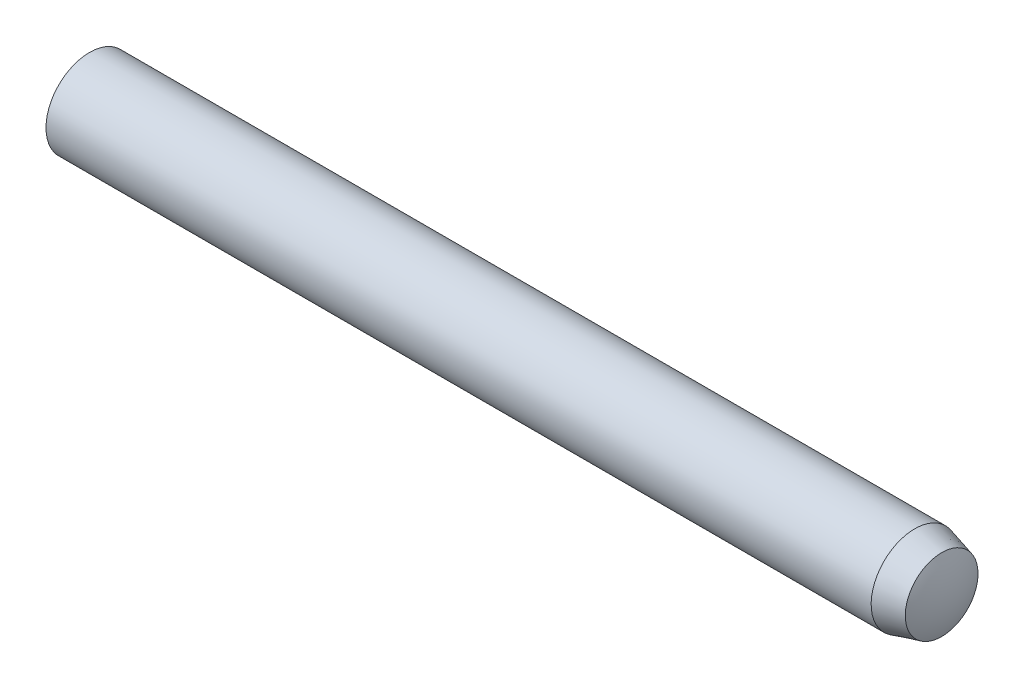
from build123d import *


with BuildPart() as part:
    # BodySke → Body (revolve)
    with BuildSketch(Plane.XY):
        with BuildLine():
            Line((28.8, 1.5), (29.726360315, 1.251782502))
            ThreePointArc((29.726360315, 1.251782502), (29.930791783, 0.640671154), (30, 0))
            Line((30, 0), (0, 0))
            ThreePointArc((0, 0), (0.101717244, 0.776208735), (0.4, 1.5))
            Line((0.4, 1.5), (28.8, 1.5))
        make_face()
    revolve(axis=Axis((0, 0, 0), (1, 0, 0)))


solid = part.part
